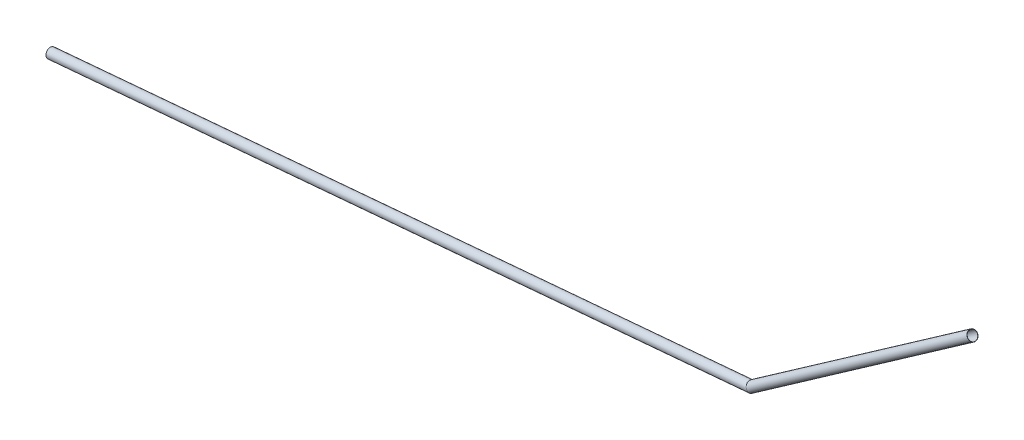
from build123d import *

# Parameters (mm, degrees)
SKETCH3_R   = 2.6
SKETCH3_R_2 = 2.5


with BuildPart() as part:
    # Sweep-Thin1: sweep along a path in Sketch2
    with BuildLine(Plane.XY) as sweep_thin1_path:
        Line((0, 0), (380, 33.24569214))
        Line((380, 33.24569214), (500, 117.270596725))
    # Sketch3 → Sweep-Thin1 (sweep)
    with BuildSketch(Plane(origin=(0, 0, 0), x_dir=(0, 0, -1), z_dir=(0.996194698, 0.087155743, 0))):
        Circle(SKETCH3_R)
        Circle(SKETCH3_R_2, mode=Mode.SUBTRACT)
    sweep(path=sweep_thin1_path.line, transition=Transition.RIGHT)


solid = part.part
